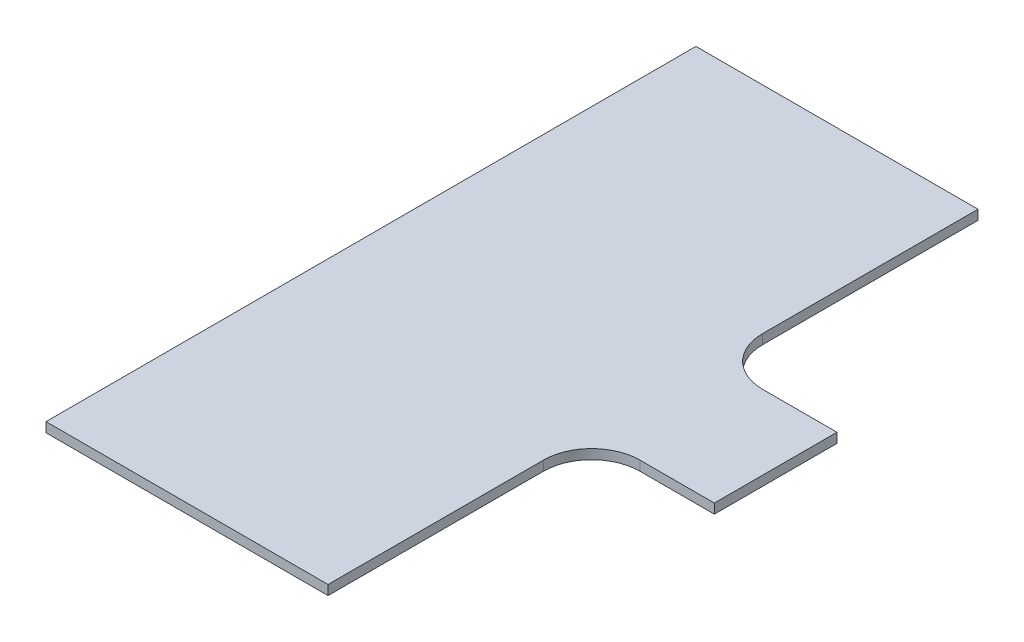
from build123d import *

# Parameters (mm, degrees)
BOSS_EXTRUDE1_DEPTH = 2


with BuildPart() as part:
    # Sketch1 → Boss-Extrude1 (new body)
    with BuildSketch(Plane(origin=(0, 0, 0), x_dir=(1, 0, 0), z_dir=(0, 1, 0))):
        with BuildLine():
            Line((-29.21, 67.31), (29.21, 67.31))
            Line((29.21, 67.31), (29.21, 22.7))
            ThreePointArc((29.21, 22.7), (32.138932188, 15.628932188), (39.21, 12.7))
            Line((39.21, 12.7), (54.61, 12.7))
            Line((54.61, 12.7), (54.61, -12.7))
            Line((54.61, -12.7), (39.21, -12.7))
            ThreePointArc((39.21, -12.7), (32.138932188, -15.628932188), (29.21, -22.7))
            Line((29.21, -22.7), (29.21, -67.31))
            Line((29.21, -67.31), (-29.21, -67.31))
            Line((-29.21, -67.31), (-29.21, 67.31))
        make_face()
    extrude(amount=BOSS_EXTRUDE1_DEPTH)


solid = part.part
